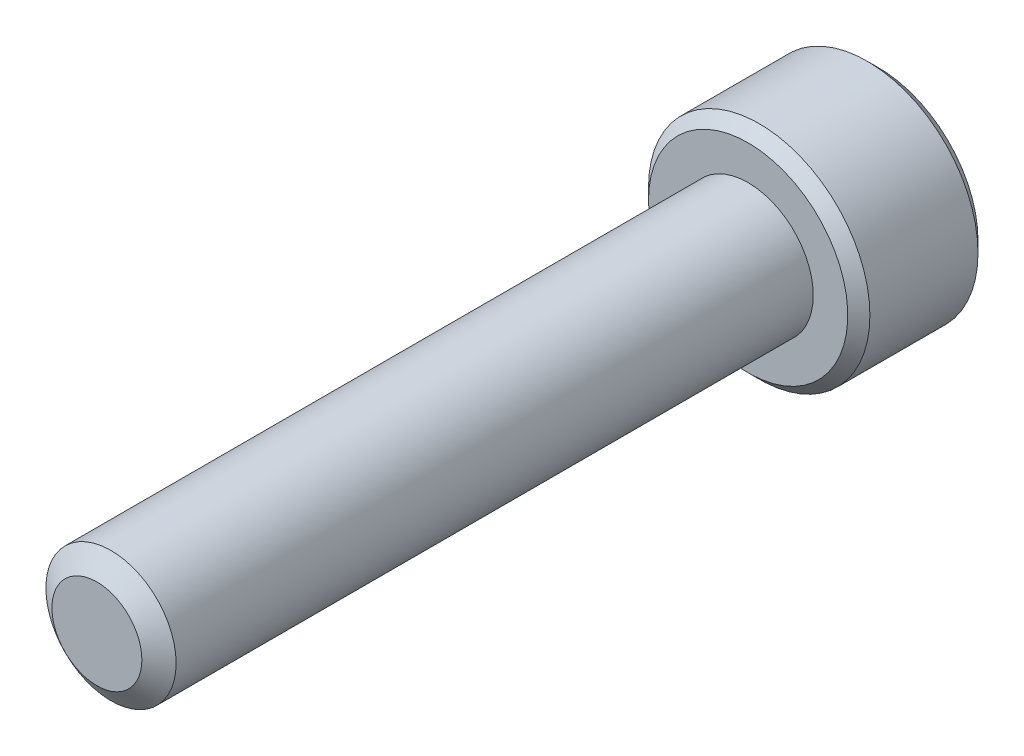
from build123d import *

# Parameters (mm, degrees)
SKETCH1_R          = 2.5
EXTRUDE1_DEPTH     = 25
SKETCH6_R          = 4.25
EXTRUDE2_DEPTH     = 5
CUT_EXTRUDE1_DEPTH = 3
CHAMFER1_SIZE      = 0.425


with BuildPart() as part:
    # Sketch1 → Extrude1 (new body)
    with BuildSketch(Plane.XY):
        Circle(SKETCH1_R)
    extrude(amount=-EXTRUDE1_DEPTH)

    # Sketch4 → Cut-Revolve1 (revolve, cut)
    with BuildSketch(Plane(origin=(0, 0, 0), x_dir=(0, 0, -1), z_dir=(1, 0, 0))):
        Polygon((0.541691224, 2.5), (0, 1.726384758), (0, 2.5), align=None)
    revolve(axis=Axis((0, 0, 0), (0, 0, -1)), mode=Mode.SUBTRACT)

    # Sketch6 → Extrude2 (add)
    with BuildSketch(Plane(origin=(0, 0, -25), x_dir=(-1, 0, 0), z_dir=(0, 0, -1))):
        Circle(SKETCH6_R)
    extrude(amount=EXTRUDE2_DEPTH)

    # Sketch7 → Cut-Extrude1 (cut)
    with BuildSketch(Plane(origin=(0, 0, -30), x_dir=(-1, 0, 0), z_dir=(0, 0, -1))):
        Polygon((0, 2.309401077), (-2, 1.154700538), (-2, -1.154700538), (0, -2.309401077), (2, -1.154700538), (2, 1.154700538), align=None)
    extrude(amount=-CUT_EXTRUDE1_DEPTH, mode=Mode.SUBTRACT)

    # Cut-Extrude2 cone 1 section (through the dimple's axis) → Cut-Extrude2 (revolve, cut)
    with BuildSketch(Plane(origin=(0, 0, -30), x_dir=(0, 1, 0), z_dir=(1, 0, 0))):
        Polygon((0, 0), (2.309401077, 0), (0, 2.309401077), align=None)
    revolve(axis=Axis((0, 0, -30), (0, 0, 1)), mode=Mode.SUBTRACT)

    # Chamfer1
    chamfer1_edges = [part.edges().sort_by_distance(p)[0] for p in [
        (4.25, 0, -30),
        (4.25, 0, -25),
    ]]
    chamfer(chamfer1_edges, length=CHAMFER1_SIZE)


solid = part.part
